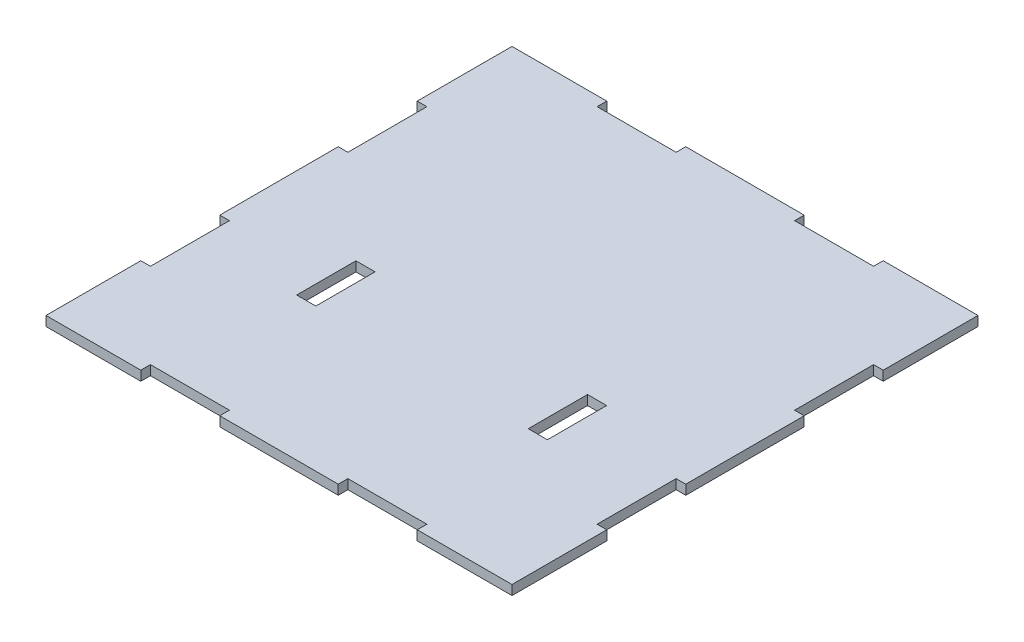
from build123d import *

# Parameters (mm, degrees)
CROQUIS1_W              = 4.84
CROQUIS1_H              = 15
SALIENTE_EXTRUIR1_DEPTH = 2.44


with BuildPart() as part:
    # Croquis1 → Saliente-Extruir1 (new body)
    with BuildSketch(Plane(origin=(0, 0, 0), x_dir=(1, 0, 0), z_dir=(0, 1, 0))):
        Polygon((-59, -59), (-35, -59), (-35, -56.56), (-15, -56.56), (-15, -59), (15, -59), (15, -56.56), (35, -56.56), (35, -59), (59, -59), (59, -35), (56.56, -35), (56.56, -15), (59, -15), (59, 15), (56.56, 15), (56.56, 35), (59, 35), (59, 59), (35, 59), (35, 56.56), (15, 56.56), (15, 59), (-15, 59), (-15, 56.56), (-35, 56.56), (-35, 59), (-59, 59), (-59, 35), (-56.56, 35), (-56.56, 15), (-59, 15), (-59, -15), (-56.56, -15), (-56.56, -35), (-59, -35), align=None)
        with Locations((-29.32, -15.28)):
            Rectangle(CROQUIS1_W, CROQUIS1_H, mode=Mode.SUBTRACT)
        with Locations((29.32, -15.28)):
            Rectangle(CROQUIS1_W, CROQUIS1_H, mode=Mode.SUBTRACT)
    extrude(amount=SALIENTE_EXTRUIR1_DEPTH)


solid = part.part
